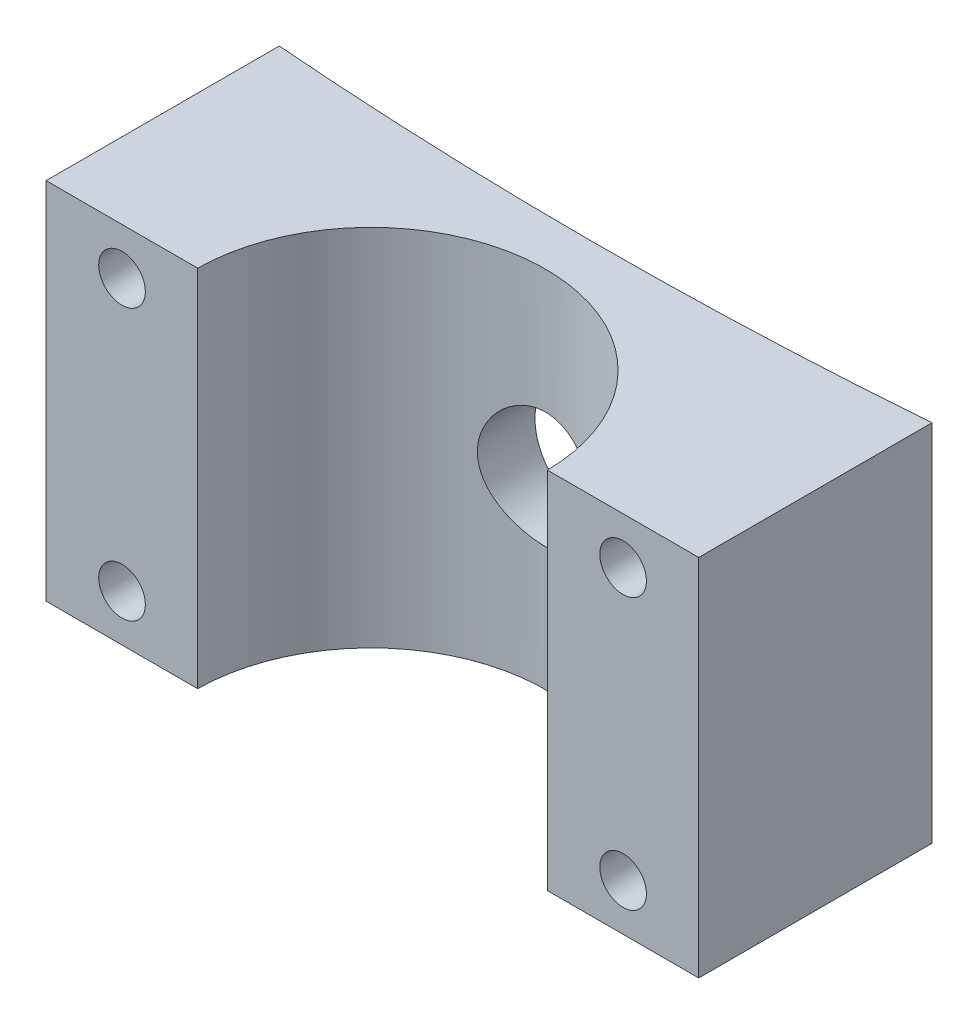
from build123d import *

# Parameters (mm, degrees)
BOSS_EXTRUDE1_DEPTH = 156.2
SKETCH5_R           = 10
CUT_EXTRUDE1_DEPTH  = 101
SKETCH6_R           = 25
CUT_EXTRUDE2_DEPTH  = 101.0000001


with BuildPart() as part:
    # Sketch1 → Boss-Extrude1 (new body)
    with BuildSketch(Plane(origin=(0, 0, 0), x_dir=(1, 0, 0), z_dir=(0, 1, 0))):
        with BuildLine():
            ThreePointArc((139.891219134, -157.482137257), (-0.054560073, -162.999999162), (-140, -157.473539028))
            Line((-140, -157.473539028), (-140, -257.473539028))
            Line((-140, -257.473539028), (-74.996125665, -257.473539028))
            ThreePointArc((-74.996125665, -257.473539028), (0, -183.235861256), (74.996125665, -257.473539028))
            Line((74.996125665, -257.473539028), (139.891219134, -257.473539028))
            Line((139.891219134, -257.473539028), (139.891219134, -157.482137257))
        make_face()
    extrude(amount=BOSS_EXTRUDE1_DEPTH)

    # Sketch5 → Cut-Extrude1 (cut, through all)
    with BuildSketch(Plane.XY.offset(257.473539028)):
        with Locations((107.4436724, 136.2)):
            Circle(SKETCH5_R)
        with Locations((107.4436724, 20)):
            Circle(SKETCH5_R)
        with Locations((-107.4436724, 20)):
            Circle(SKETCH5_R)
        with Locations((-107.4436724, 136.2)):
            Circle(SKETCH5_R)
    extrude(amount=-CUT_EXTRUDE1_DEPTH, mode=Mode.SUBTRACT)

    # Sketch6 → Cut-Extrude2 (cut, through all)
    with BuildSketch(Plane.XY.offset(257.473539028)):
        with Locations((0, 78.1)):
            Circle(SKETCH6_R)
    extrude(amount=-CUT_EXTRUDE2_DEPTH, mode=Mode.SUBTRACT)


solid = part.part
